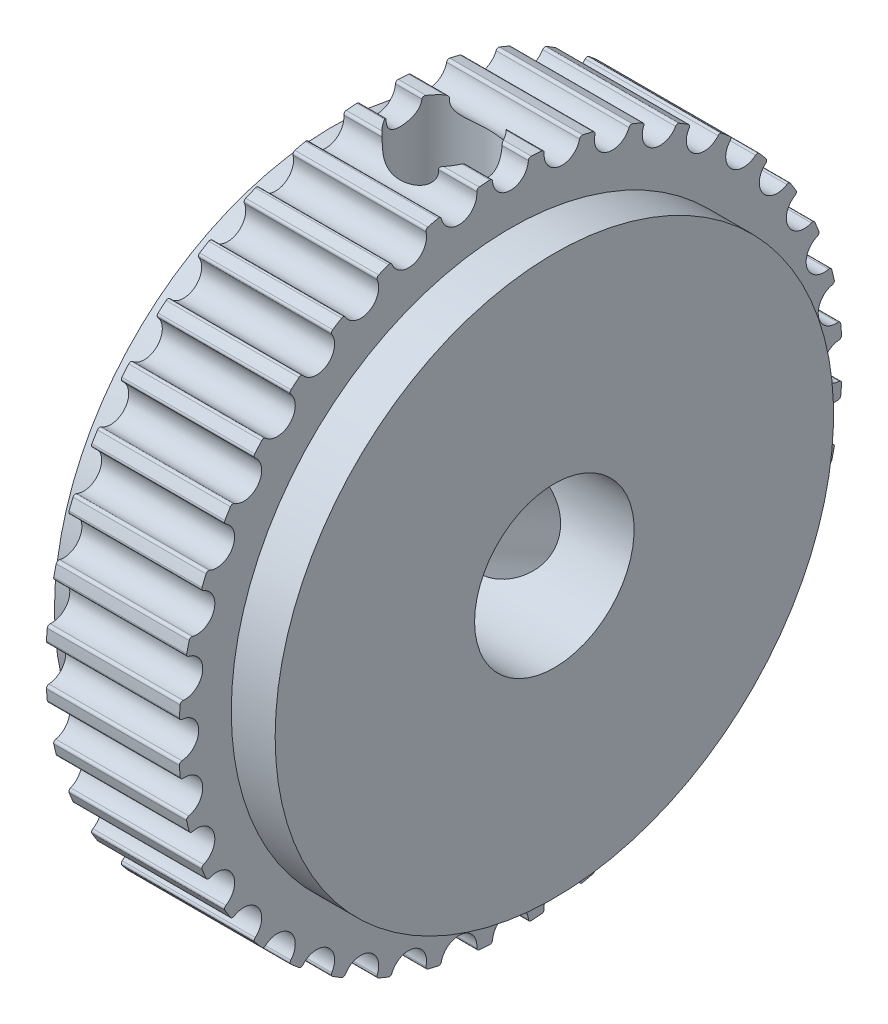
from build123d import *

# Parameters (mm, degrees)
CUT_EXTRUDE1_DEPTH       = 19.854011509
FILLET1_R                = 0.1
CIRPATTERN1_COUNT        = 40
FILLET1_OF_CIRPATTERN1_R = 0.1
TAPPED_HOLE1_REACH       = 43.913
TAPPED_HOLE1_BORE_R      = 1.65
CIRPATTERN2_COUNT        = 2
CIRPATTERN2_ANGLE        = 120


with BuildPart() as part:
    # Sketch1 → Revolve1 (revolve)
    with BuildSketch(Plane.XY, mode=Mode.PRIVATE) as revolve1_sk:
        Polygon((1.65, 12.475), (6.65, 12.475), (6.65, 10.5), (8.3, 10.5), (8.3, 3), (0, 3), (0, 10.5), (1.65, 10.5), align=None)
    revolve(revolve1_sk.sketch.rotate(Axis((0, 0, 0), (1, 0, 0)), 90), axis=Axis((0, 0, 0), (1, 0, 0)))

    # Sketch2 → Cut-Extrude1 (cut, through all)
    with BuildSketch(Plane(origin=(1.65, 0, 0), x_dir=(0, 0, -1), z_dir=(1, 0, 0))):
        with BuildLine():
            ThreePointArc((0.672601314, 12.456854839), (0, 12.475), (-0.672601314, 12.456854839))
            ThreePointArc((-0.672601314, 12.456854839), (0, 11.725), (0.672601314, 12.456854839))
        make_face()
    cut_extrude1 = extrude(amount=CUT_EXTRUDE1_DEPTH, mode=Mode.SUBTRACT)

    # Fillet1
    fillet1_edges = [part.edges().sort_by_distance(p)[0] for p in [
        (4.15, 12.456854839, 0.672601314),
        (4.15, 12.456854839, -0.672601314),
    ]]
    fillet(fillet1_edges, radius=FILLET1_R)

    # CirPattern1: Cut-Extrude1 ×40 about axis
    cirpattern1_axis = Axis((0, 0, 0), (1, 0, 0))
    for i in range(1, CIRPATTERN1_COUNT):
        add(cut_extrude1.rotate(cirpattern1_axis, i * 360 / CIRPATTERN1_COUNT), mode=Mode.SUBTRACT)

    # Fillet1 of CirPattern1
    fillet1_of_cirpattern1_edges = [part.edges().sort_by_distance(p)[0] for p in [
        (4.15, 12.198272258, 2.613001898),
        (4.15, 12.408708311, 1.284360947),
        (4.15, 11.63932773, 4.489061704),
        (4.15, 12.055018203, 3.209697979),
        (4.15, 10.793784326, 6.254585912),
        (4.15, 11.404493539, 5.056001595),
        (4.15, 9.682462128, 7.866101457),
        (4.15, 10.473152394, 6.777809671),
        (4.15, 8.332725579, 9.283927479),
        (4.15, 9.283927479, 8.332725579),
        (4.15, 6.777809671, 10.473152394),
        (4.15, 7.866101457, 9.682462128),
        (4.15, 5.056001595, 11.404493539),
        (4.15, 6.254585912, 10.793784326),
        (4.15, 3.209697979, 12.055018203),
        (4.15, 4.489061704, 11.63932773),
        (4.15, 1.284360947, 12.408708311),
        (4.15, 2.613001898, 12.198272258),
        (4.15, -0.672601314, 12.456854839),
        (4.15, 0.672601314, 12.456854839),
        (4.15, -2.613001898, 12.198272258),
        (4.15, -1.284360947, 12.408708311),
        (4.15, -4.489061704, 11.63932773),
        (4.15, -3.209697979, 12.055018203),
        (4.15, -6.254585912, 10.793784326),
        (4.15, -5.056001595, 11.404493539),
        (4.15, -7.866101457, 9.682462128),
        (4.15, -6.777809671, 10.473152394),
        (4.15, -9.283927479, 8.332725579),
        (4.15, -8.332725579, 9.283927479),
        (4.15, -10.473152394, 6.777809671),
        (4.15, -9.682462128, 7.866101457),
        (4.15, -11.404493539, 5.056001595),
        (4.15, -10.793784326, 6.254585912),
        (4.15, -12.055018203, 3.209697979),
        (4.15, -11.63932773, 4.489061704),
        (4.15, -12.408708311, 1.284360947),
        (4.15, -12.198272258, 2.613001898),
        (4.15, -12.456854839, -0.672601314),
        (4.15, -12.456854839, 0.672601314),
        (4.15, -12.198272258, -2.613001898),
        (4.15, -12.408708311, -1.284360947),
        (4.15, -11.63932773, -4.489061704),
        (4.15, -12.055018203, -3.209697979),
        (4.15, -10.793784326, -6.254585912),
        (4.15, -11.404493539, -5.056001595),
        (4.15, -9.682462128, -7.866101457),
        (4.15, -10.473152394, -6.777809671),
        (4.15, -8.332725579, -9.283927479),
        (4.15, -9.283927479, -8.332725579),
        (4.15, -6.777809671, -10.473152394),
        (4.15, -7.866101457, -9.682462128),
        (4.15, -5.056001595, -11.404493539),
        (4.15, -6.254585912, -10.793784326),
        (4.15, -3.209697979, -12.055018203),
        (4.15, -4.489061704, -11.63932773),
        (4.15, -1.284360947, -12.408708311),
        (4.15, -2.613001898, -12.198272258),
        (4.15, 0.672601314, -12.456854839),
        (4.15, -0.672601314, -12.456854839),
        (4.15, 2.613001898, -12.198272258),
        (4.15, 1.284360947, -12.408708311),
        (4.15, 4.489061704, -11.63932773),
        (4.15, 3.209697979, -12.055018203),
        (4.15, 6.254585912, -10.793784326),
        (4.15, 5.056001595, -11.404493539),
        (4.15, 7.866101457, -9.682462128),
        (4.15, 6.777809671, -10.473152394),
        (4.15, 9.283927479, -8.332725579),
        (4.15, 8.332725579, -9.283927479),
        (4.15, 10.473152394, -6.777809671),
        (4.15, 9.682462128, -7.866101457),
        (4.15, 11.404493539, -5.056001595),
        (4.15, 10.793784326, -6.254585912),
        (4.15, 12.055018203, -3.209697979),
        (4.15, 11.63932773, -4.489061704),
        (4.15, 12.408708311, -1.284360947),
        (4.15, 12.198272258, -2.613001898),
    ]]
    fillet(fillet1_of_cirpattern1_edges, radius=FILLET1_OF_CIRPATTERN1_R)

    # Tapped Hole1 bore → Tapped Hole1 (cut, up to next)
    with BuildSketch(Plane(origin=(-11.091537855, 12.475, -15.10513819), x_dir=(1, 0, 0), z_dir=(0, 1, 0)), mode=Mode.PRIVATE) as tapped_hole1_sk1:
        with Locations((15.241537855, -15.10513819)):
            Circle(TAPPED_HOLE1_BORE_R)
    tapped_hole1_tool1 = extrude(tapped_hole1_sk1.sketch, amount=-TAPPED_HOLE1_REACH, mode=Mode.PRIVATE) & part.part
    tapped_hole1 = tapped_hole1_tool1.solids().sort_by_distance((4.15, 12.475, 0))[0]
    add(tapped_hole1, mode=Mode.SUBTRACT)

    # CirPattern2: Tapped Hole1; each copy of Tapped Hole1 runs up to whatever stops it at its own place
    cirpattern2_before = part.part  # the part as the pattern finds it: every copy runs up to it
    cirpattern2_tapped_hole1_long = extrude(tapped_hole1_sk1.sketch, amount=-TAPPED_HOLE1_REACH, mode=Mode.PRIVATE)
    cirpattern2_tapped_hole1_tool = cirpattern2_tapped_hole1_long.rotate(Axis((0, 0, 0), (-1, 0, 0)), 1 * CIRPATTERN2_ANGLE / (CIRPATTERN2_COUNT - 1)) & cirpattern2_before
    add(cirpattern2_tapped_hole1_tool.solids().sort_by_distance((4.15, -6.2375, -10.803667))[0], mode=Mode.SUBTRACT)


solid = part.part
